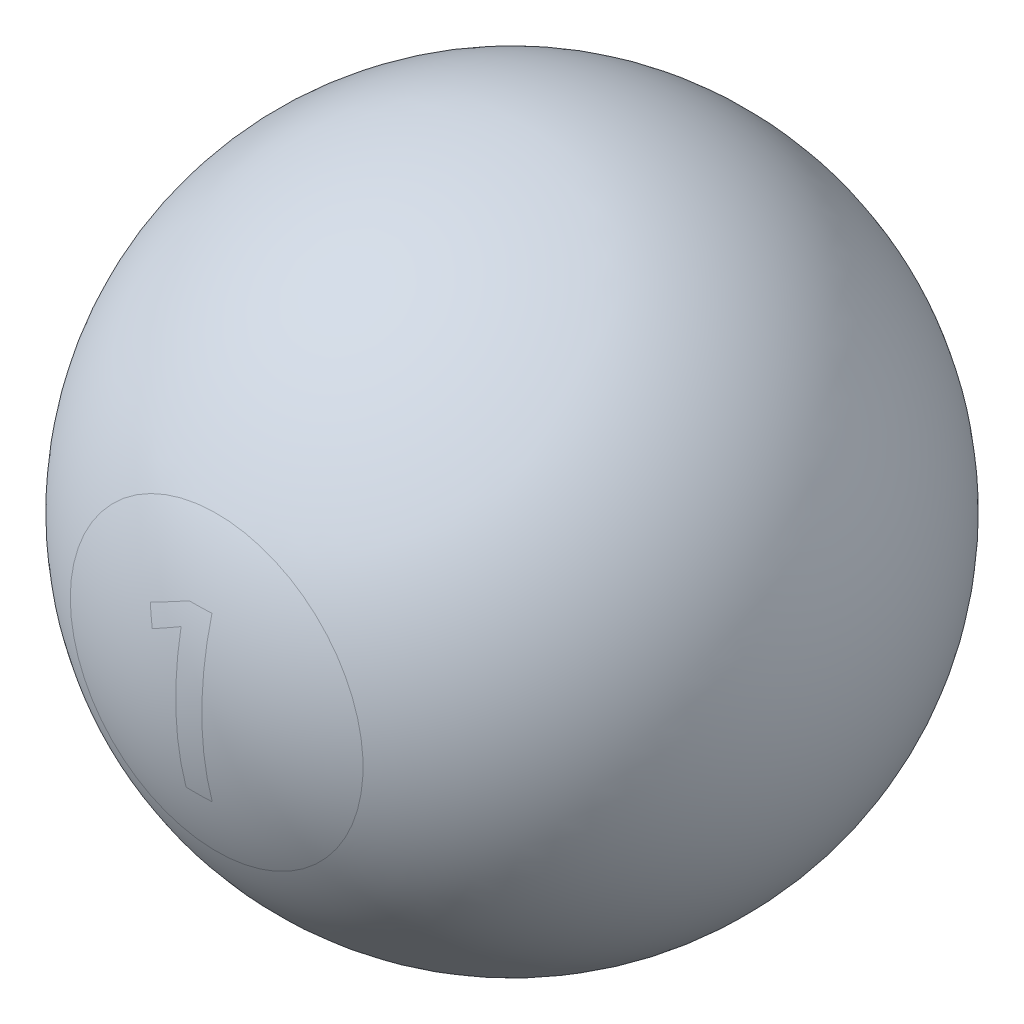
from build123d import *

# Parameters (mm, degrees)
SKIZZEKREIS_R                      = 12.7
SCHNITTKREIS_DEPTH                 = 50.536653096
SCHNITTKREIS_DEPTH_BACK            = 50.536653096
AUFSATZKREIS_REACH                 = 51.537
AUFSATZKREIS_END_RADIUS            = 28.6
SKIZZEKREIS_3_R                    = 12.7
SCHNITTNUMMER_START                = 20
SCHNITTNUMMER_DEPTH                = 30.536653096
KREISMUSTERKREIS_COUNT             = 2
KREISMUSTERKREIS_2_COUNT           = 2
AUFSATZNUMMER_REACH                = 71.537
AUFSATZNUMMER_END_RADIUS           = 28.6
AUFSATZNUMMER_START                = 20
AUFSATZNUMMERGESPIEGELT_REACH      = 71.537
AUFSATZNUMMERGESPIEGELT_END_RADIUS = 28.6
AUFSATZNUMMERGESPIEGELT_START      = 20


with BuildPart() as part:
    # SkizzeRotation → Rotation1 (revolve)
    with BuildSketch(Plane.XY):
        with BuildLine():
            Line((0, 28.6), (0, -28.6))
            ThreePointArc((0, -28.6), (-28.6, 0), (0, 28.6))
        make_face()
    revolve(axis=Axis((0, 28.6, 0), (0, -1, 0)))

    # SkizzeKreis → SchnittKreis (cut, two sides)
    with BuildSketch(Plane.XY) as schnittkreis_sk:
        with Locations(Location((0, 0, 0), (0, 0, 180))):
            Circle(SKIZZEKREIS_R)
    extrude(amount=SCHNITTKREIS_DEPTH, mode=Mode.SUBTRACT)
    extrude(schnittkreis_sk.sketch, amount=-SCHNITTKREIS_DEPTH_BACK, mode=Mode.SUBTRACT)


with BuildPart() as body_2:
    # AufsatzKreis: up to this sphere (the profile starts inside it)
    aufsatzkreis_end = Location((0, 0, 0)) * Sphere(AUFSATZKREIS_END_RADIUS, mode=Mode.PRIVATE)
    # SkizzeKreis_3 → AufsatzKreis (new, up to the surface)
    with BuildSketch(Plane.XY, mode=Mode.PRIVATE) as aufsatzkreis_sk1:
        with Locations(Location((0, 0, 0), (0, 0, 180))):
            Circle(SKIZZEKREIS_3_R)
    aufsatzkreis_tool1 = extrude(aufsatzkreis_sk1.sketch, amount=AUFSATZKREIS_REACH, mode=Mode.PRIVATE) & aufsatzkreis_end
    aufsatzkreis = aufsatzkreis_tool1.solids().sort_by_distance((0, 0, 0))[0]
    add(aufsatzkreis)

    # SkizzeNummer → SchnittNummer (cut, through all)
    with BuildSketch(Plane.XY.offset(SCHNITTNUMMER_START)):
        Polygon((1.638511262, -7.139040058), (1.638511262, 7.043121636), (-0.290941495, 7.043121636), (-3.521916746, 5.405966988), (-3.0295007, 3.810353622), (-0.624237706, 5.13608913), (-0.586359549, 5.13608913), (-0.586359549, -7.117494783), align=None)
    schnittnummer = extrude(amount=SCHNITTNUMMER_DEPTH, mode=Mode.SUBTRACT)

    # KreismusterKreis: AufsatzKreis ×2 about axis
    kreismusterkreis_axis = Axis((0, 0, 0), (0, 1, 0))
    for i in range(1, KREISMUSTERKREIS_COUNT):
        add(aufsatzkreis.rotate(kreismusterkreis_axis, i * 360 / KREISMUSTERKREIS_COUNT))

    # KreismusterKreis 2: SchnittNummer ×2 about axis
    kreismusterkreis_2_axis = Axis((0, 0, 0), (0, 1, 0))
    for i in range(1, KREISMUSTERKREIS_2_COUNT):
        add(schnittnummer.rotate(kreismusterkreis_2_axis, i * 360 / KREISMUSTERKREIS_2_COUNT), mode=Mode.SUBTRACT)


with BuildPart() as body_3:
    # AufsatzNummer: up to this sphere (the profile starts inside it)
    aufsatznummer_end = Location((0, 0, 0)) * Sphere(AUFSATZNUMMER_END_RADIUS, mode=Mode.PRIVATE)
    # SkizzeNummer_4 → AufsatzNummer (new, up to the surface)
    with BuildSketch(Plane.XY.offset(AUFSATZNUMMER_START), mode=Mode.PRIVATE) as aufsatznummer_sk1:
        Polygon((1.638511262, -7.139040058), (1.638511262, 7.043121636), (-0.290941495, 7.043121636), (-3.521916746, 5.405966988), (-3.0295007, 3.810353622), (-0.624237706, 5.13608913), (-0.586359549, 5.13608913), (-0.586359549, -7.117494783), align=None)
    aufsatznummer_tool1 = extrude(aufsatznummer_sk1.sketch, amount=AUFSATZNUMMER_REACH, mode=Mode.PRIVATE) & aufsatznummer_end
    add(aufsatznummer_tool1.solids().sort_by_distance((0.19791, 0.66771, 20))[0])


with BuildPart() as body_4:
    # AufsatzNummerGespiegelt: up to this sphere (the profile starts inside it)
    aufsatznummergespiegelt_end = Location((0, 0, 0)) * Sphere(AUFSATZNUMMERGESPIEGELT_END_RADIUS, mode=Mode.PRIVATE)
    # Skizze7 → AufsatzNummerGespiegelt (new, up to the surface)
    with BuildSketch(Plane(origin=(0, 0, 0), x_dir=(-1, 0, 0), z_dir=(0, 0, -1)).offset(AUFSATZNUMMERGESPIEGELT_START), mode=Mode.PRIVATE) as aufsatznummergespiegelt_sk1:
        Polygon((1.638511262, -7.139040058), (1.638511262, 7.043121636), (-0.290941495, 7.043121636), (-3.521916746, 5.405966988), (-3.0295007, 3.810353622), (-0.624237706, 5.13608913), (-0.586359549, 5.13608913), (-0.586359549, -7.117494783), align=None)
    aufsatznummergespiegelt_tool1 = extrude(aufsatznummergespiegelt_sk1.sketch, amount=AUFSATZNUMMERGESPIEGELT_REACH, mode=Mode.PRIVATE) & aufsatznummergespiegelt_end
    add(aufsatznummergespiegelt_tool1.solids().sort_by_distance((-0.19791, 0.66771, -20))[0])


solid = Compound([part.part, body_2.part, body_3.part, body_4.part])
